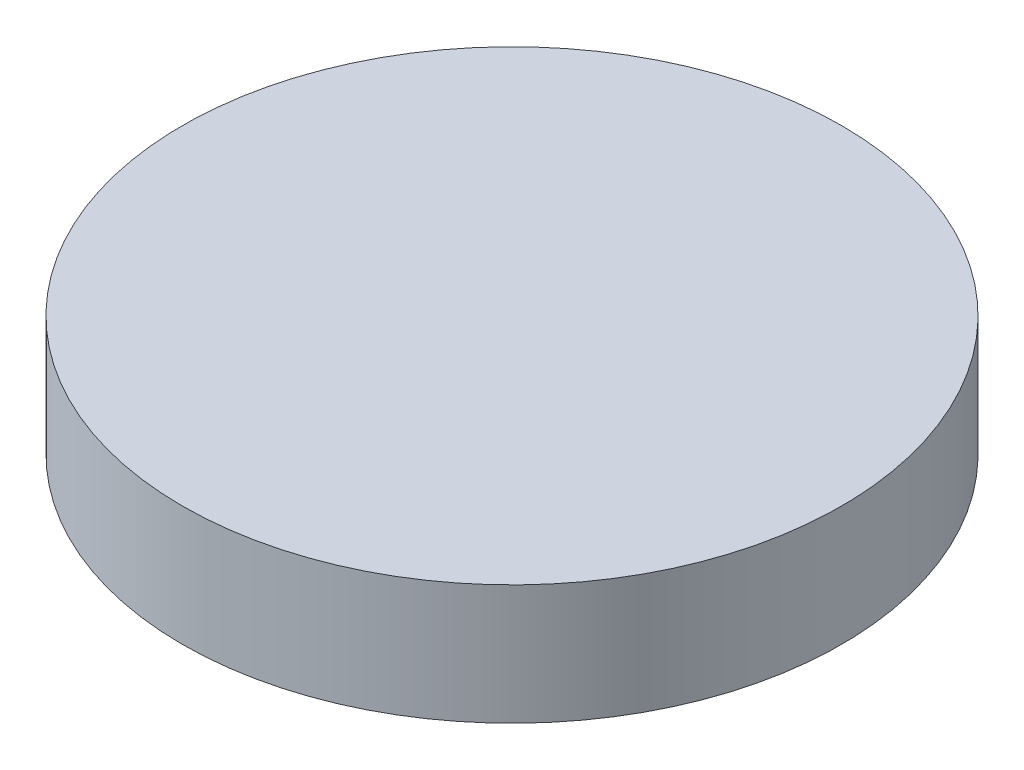
from build123d import *

# Parameters (mm, degrees)
SKETCH1_R      = 110
EXTRUDE1_DEPTH = 40


with BuildPart() as part:
    # Sketch1 → Extrude1 (new body)
    with BuildSketch(Plane(origin=(0, 0, 0), x_dir=(1, 0, 0), z_dir=(0, 1, 0))):
        with Locations(Location((0, 0, 0), (0, 0, 270))):  # turned: the seam where the file's is
            Circle(SKETCH1_R)
    extrude(amount=EXTRUDE1_DEPTH)


solid = part.part
